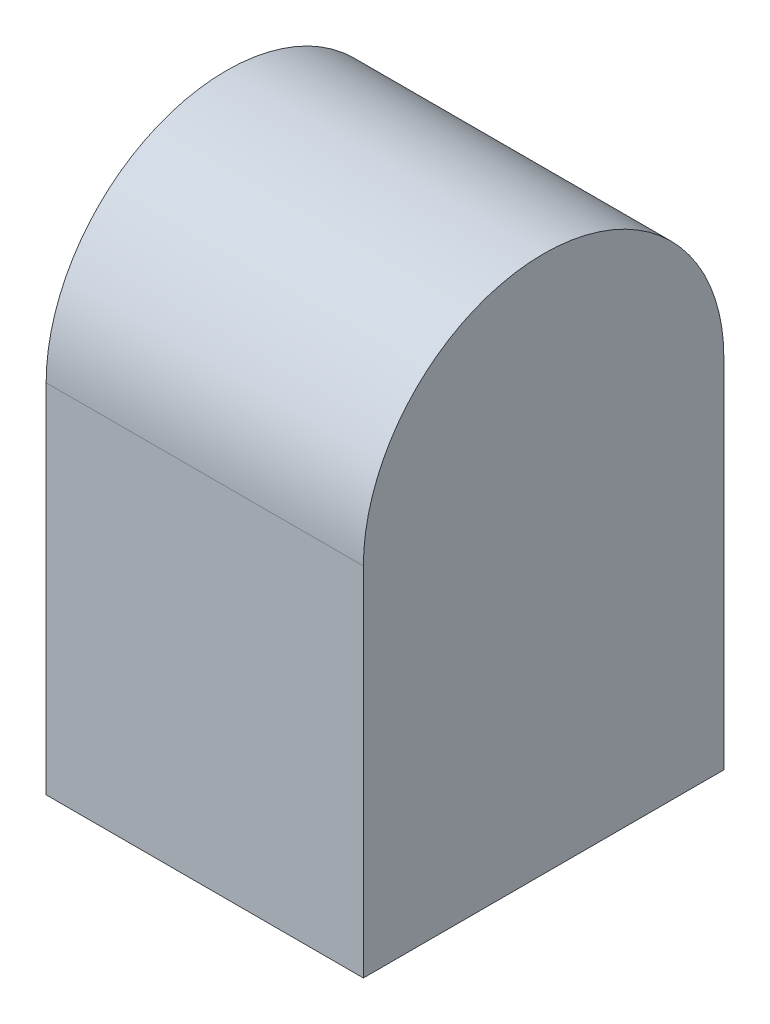
from build123d import *

# Parameters (mm, degrees)
SKETCH1_W           = 0.044
SKETCH1_H           = 0.05
BOSS_EXTRUDE1_DEPTH = 0.0495
SKETCH3_R           = 0.025
BOSS_EXTRUDE2_DEPTH = 0.044


with BuildPart() as part:
    # Sketch1 → Boss-Extrude1 (new body)
    with BuildSketch(Plane(origin=(0, 0, 0), x_dir=(1, 0, 0), z_dir=(0, 1, 0))):
        with Locations((0.022, 0.025)):
            Rectangle(SKETCH1_W, SKETCH1_H)
    extrude(amount=BOSS_EXTRUDE1_DEPTH)

    # Sketch3 → Boss-Extrude2 (add)
    with BuildSketch(Plane.ZY):
        with Locations((-0.025, 0.0495)):
            Circle(SKETCH3_R)
    extrude(amount=-BOSS_EXTRUDE2_DEPTH)


solid = part.part
